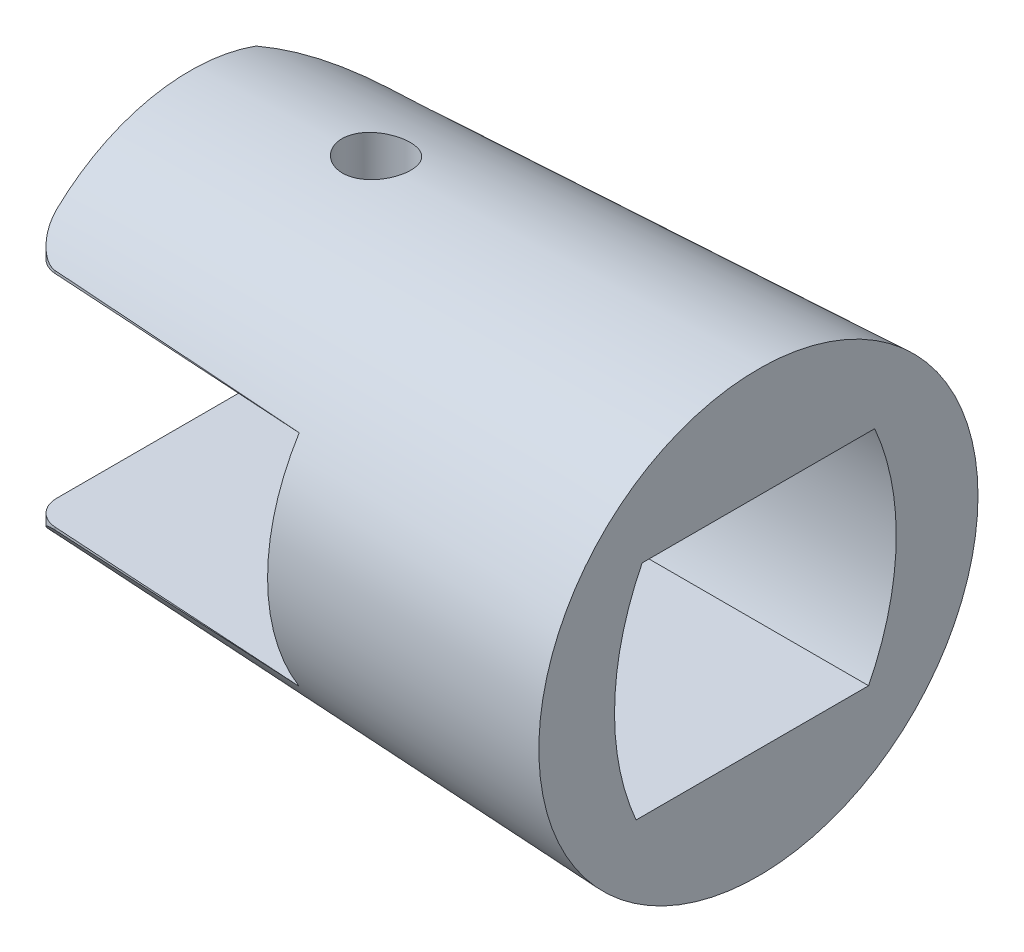
from build123d import *

# Parameters (mm, degrees)
SKETCH4_R               = 7.5
SKETCH1_R               = 8.5
SKETCH5_W               = 13.984772719
SKETCH5_H               = 8.5
CUT_EXTRUDE1_DEPTH      = 10
CUT_EXTRUDE1_DEPTH_BACK = 10
CUT_EXTRUDE2_DEPTH      = 10
CUT_EXTRUDE2_DEPTH_BACK = 10
SKETCH8_R               = 1.25
CUT_EXTRUDE3_DEPTH      = 10
CUT_EXTRUDE3_DEPTH_BACK = 10
CUT_EXTRUDE4_DEPTH      = 12
FILLET1_R               = 1


with BuildPart() as part:
    # Sketch4 → Loft1 section 0
    with BuildSketch(Plane(origin=(-22, 0, 0), x_dir=(0, 0, -1), z_dir=(1, 0, 0))):
        Circle(SKETCH4_R)
    # Sketch1 → Loft1 section 1
    with BuildSketch(Plane(origin=(0, 0, 0), x_dir=(0, 0, -1), z_dir=(1, 0, 0))):
        Circle(SKETCH1_R)
    loft()

    # Sketch5 → Cut-Extrude1 (cut, two sides)
    with BuildSketch(Plane.XY) as cut_extrude1_sk:
        with Locations((-17.99238636, 0)):
            Rectangle(SKETCH5_W, SKETCH5_H)
    extrude(amount=CUT_EXTRUDE1_DEPTH, mode=Mode.SUBTRACT)
    extrude(cut_extrude1_sk.sketch, amount=-CUT_EXTRUDE1_DEPTH_BACK, mode=Mode.SUBTRACT)

    # Sketch7 → Cut-Extrude2 (cut, two sides)
    with BuildSketch(Plane(origin=(0, 0, 0), x_dir=(1, 0, 0), z_dir=(0, 1, 0))) as cut_extrude2_sk:
        with BuildLine():
            ThreePointArc((-16.527422763, 6.684642149), (-21.211826581, 3.739953342), (-23.023054805, -1.488266586))
            Line((-23.023054805, -1.488266586), (-23.002284576, -6.042868806))
            Line((-23.002284576, -6.042868806), (-11, -6.777720856))
            Line((-11, -6.777720856), (-11, -8.501479668))
            Line((-11, -8.501479668), (-27.91814199, -8.501479668))
            Line((-27.91814199, -8.501479668), (-27.91814199, 10.370496294))
            Line((-27.91814199, 10.370496294), (-11, 10.370496294))
            Line((-11, 10.370496294), (-11, 6.777720856))
            Line((-11, 6.777720856), (-16.527422763, 6.684642149))
        make_face()
    extrude(amount=CUT_EXTRUDE2_DEPTH, mode=Mode.SUBTRACT)
    extrude(cut_extrude2_sk.sketch, amount=-CUT_EXTRUDE2_DEPTH_BACK, mode=Mode.SUBTRACT)

    # Sketch8 → Cut-Extrude3 (cut, two sides)
    with BuildSketch(Plane(origin=(0, 0, 0), x_dir=(1, 0, 0), z_dir=(0, 1, 0))) as cut_extrude3_sk:
        with Locations((-15.3, 0.5)):
            Circle(SKETCH8_R)
    extrude(amount=CUT_EXTRUDE3_DEPTH, mode=Mode.SUBTRACT)
    extrude(cut_extrude3_sk.sketch, amount=-CUT_EXTRUDE3_DEPTH_BACK, mode=Mode.SUBTRACT)

    # Sketch10 → Cut-Extrude4 (cut)
    with BuildSketch(Plane(origin=(0, 0, 0), x_dir=(0, 0, -1), z_dir=(1, 0, 0))):
        with BuildLine():
            Line((-4.5, 4.25), (4.5, 4.25))
            ThreePointArc((4.5, 4.25), (5.331033358, -0.026207333), (4.26513416, -4.25))
            Line((4.26513416, -4.25), (-4.73486584, -4.25))
            ThreePointArc((-4.73486584, -4.25), (-5.565899198, 0.026207333), (-4.5, 4.25))
        make_face()
    extrude(amount=-CUT_EXTRUDE4_DEPTH, mode=Mode.SUBTRACT)

    # Fillet1
    fillet1_edges = [part.edges().sort_by_distance(p)[0] for p in [
        (-22, -4.303779405, 6.104234696),
        (-22, 4.303779405, 6.104234696),
    ]]
    fillet(fillet1_edges, radius=FILLET1_R)


solid = part.part
